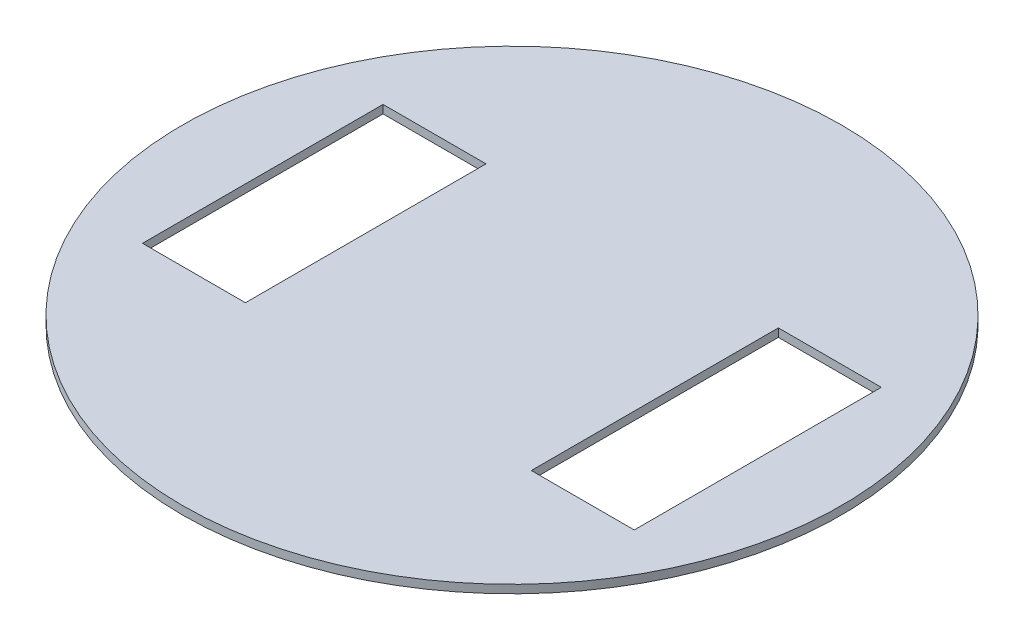
from build123d import *

# Parameters (mm, degrees)
SKETCH1_R           = 101.639987753
SKETCH1_W           = 31.75
SKETCH1_H           = 74.194618262
SKETCH1_H_2         = 76.2
BOSS_EXTRUDE1_DEPTH = 2.54


with BuildPart() as part:
    # Sketch1 → Boss-Extrude1 (new body)
    with BuildSketch(Plane(origin=(0, 0, 0), x_dir=(1, 0, 0), z_dir=(0, 1, 0))):
        Circle(SKETCH1_R)
        with Locations((-60.325, -0.669632559)):
            Rectangle(SKETCH1_W, SKETCH1_H, mode=Mode.SUBTRACT)
        with Locations((60.325, -0.401779535)):
            Rectangle(SKETCH1_W, SKETCH1_H_2, mode=Mode.SUBTRACT)
    extrude(amount=BOSS_EXTRUDE1_DEPTH)


solid = part.part
